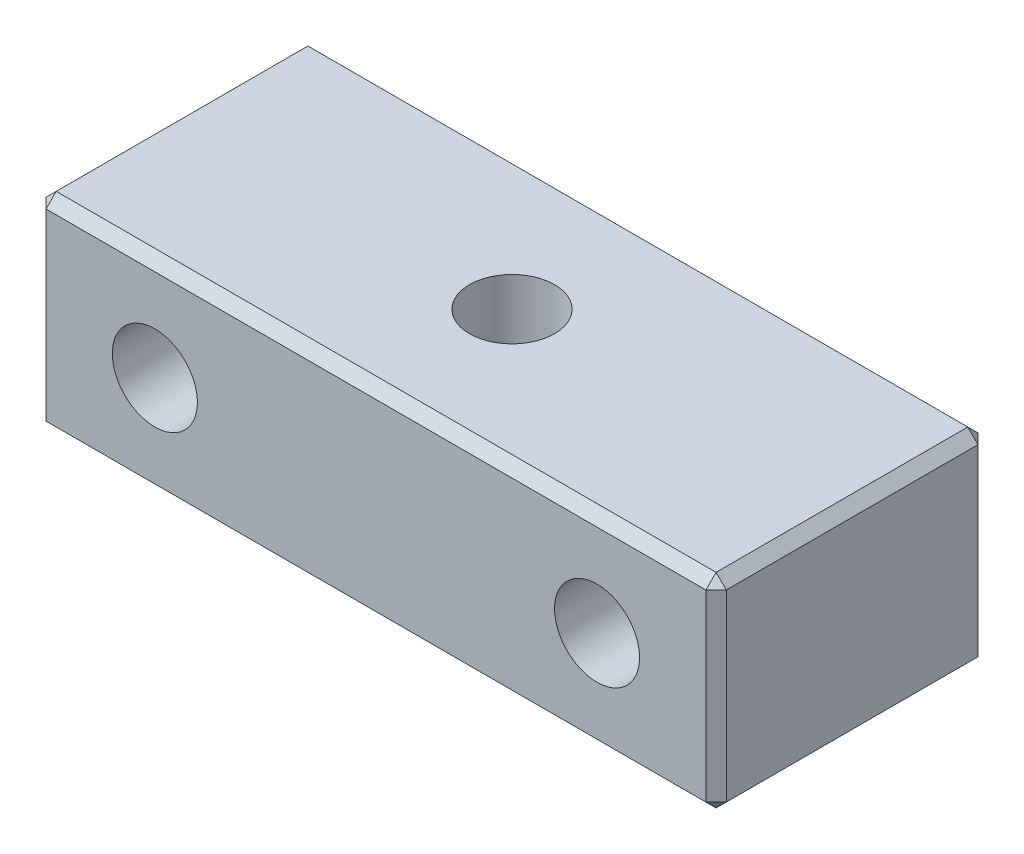
from build123d import *

# Parameters (mm, degrees)
SKETCH_1_W         = 20
SKETCH_1_H         = 8
EXTRUDE_1_DEPTH    = 6
HOLE_WIZARD_M3_1_D = 2.5
HOLE_WIZARD_M3_2_D = 2.5
CHAMFER_1_SIZE     = 0.3


with BuildPart() as part:
    # 草图1 → 凸台-拉伸1 (new body)
    with BuildSketch(Plane(origin=(0, 0, 0), x_dir=(1, 0, 0), z_dir=(0, 1, 0))):
        Rectangle(SKETCH_1_W, SKETCH_1_H)
    extrude(amount=EXTRUDE_1_DEPTH)

    # M3 螺纹孔1 (through all)
    with Locations(Plane(origin=(6.5, 3, -4), x_dir=(-1, 0, 0), z_dir=(0, 0, -1))):
        with Locations((0, 0), (13, 0)):
            Hole(HOLE_WIZARD_M3_1_D / 2)

    # M3 螺纹孔2 (through all)
    with Locations(Plane.ZX.offset(6)):
        with Locations((0, 0)):
            Hole(HOLE_WIZARD_M3_2_D / 2)

    # 倒角1
    chamfer_1_edges = [part.edges().sort_by_distance(p)[0] for p in [
        (-10, 6, 0),
        (0, 6, 4),
        (10, 6, 0),
        (0, 0, 4),
        (-10, 0, 0),
        (0, 0, -4),
        (10, 0, 0),
        (10, 3, 4),
        (-10, 3, 4),
        (-10, 3, -4),
        (10, 3, -4),
        (0, 6, -4),
    ]]
    chamfer(chamfer_1_edges, length=CHAMFER_1_SIZE)


solid = part.part
